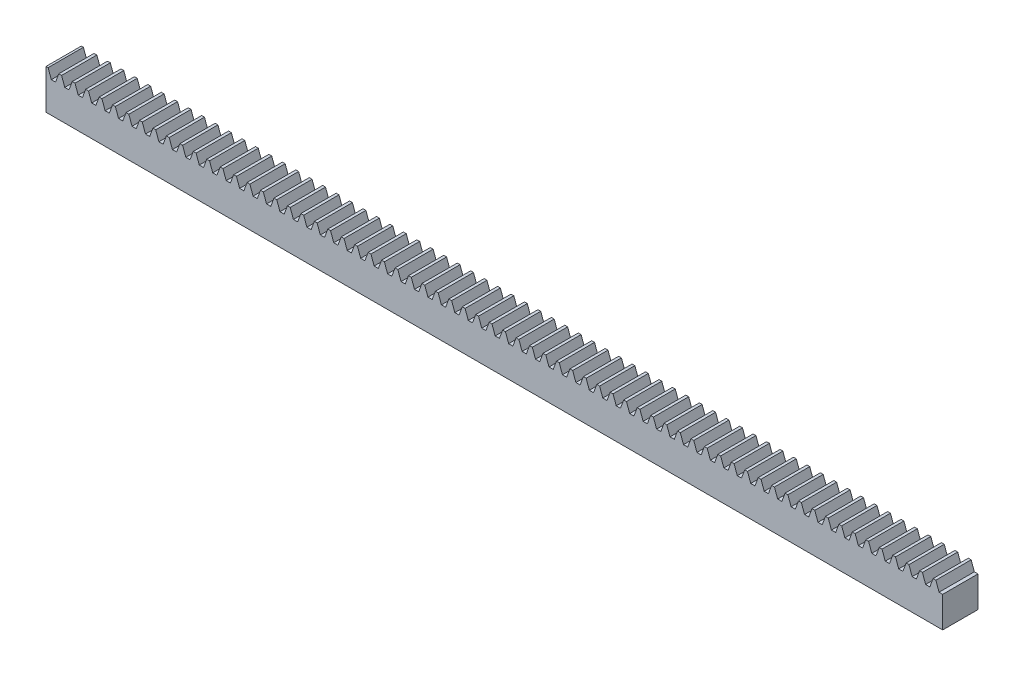
from build123d import *

# Parameters (mm, degrees)
SKETCH1_W           = 101.6
SKETCH1_H           = 4
BOSS_EXTRUDE1_DEPTH = 4.5
CUT_EXTRUDE1_DEPTH  = 5


with BuildPart() as part:
    # Sketch1 → Boss-Extrude1 (new body)
    with BuildSketch(Plane(origin=(0, 0, 0), x_dir=(1, 0, 0), z_dir=(0, 1, 0))):
        with Locations((50.8, 2)):
            Rectangle(SKETCH1_W, SKETCH1_H)
    extrude(amount=BOSS_EXTRUDE1_DEPTH)

    # Sketch2 → Cut-Extrude1 (cut, through all)
    with BuildSketch(Plane.XY):
        Polygon((0.239013956, 4.5), (0.60298419, 3.5), (0.841998146, 3.5), (1.081012101, 3.5), (1.444982335, 4.5), align=None)
        Polygon((1.763013956, 4.5), (2.12698419, 3.5), (2.365998146, 3.5), (2.605012101, 3.5), (2.968982335, 4.5), align=None)
        Polygon((3.287013956, 4.5), (3.65098419, 3.5), (3.889998146, 3.5), (4.129012101, 3.5), (4.492982335, 4.5), align=None)
        Polygon((4.811013956, 4.5), (5.17498419, 3.5), (5.413998146, 3.5), (5.653012101, 3.5), (6.016982335, 4.5), align=None)
        Polygon((6.335013956, 4.5), (6.69898419, 3.5), (6.937998146, 3.5), (7.177012101, 3.5), (7.540982335, 4.5), align=None)
        Polygon((7.859013956, 4.5), (8.22298419, 3.5), (8.461998146, 3.5), (8.701012101, 3.5), (9.064982335, 4.5), align=None)
        Polygon((9.383013956, 4.5), (9.74698419, 3.5), (9.985998146, 3.5), (10.225012101, 3.5), (10.588982335, 4.5), align=None)
        Polygon((10.907013956, 4.5), (11.27098419, 3.5), (11.509998146, 3.5), (11.749012101, 3.5), (12.112982335, 4.5), align=None)
        Polygon((12.431013956, 4.5), (12.79498419, 3.5), (13.033998146, 3.5), (13.273012101, 3.5), (13.636982335, 4.5), align=None)
        Polygon((13.955013956, 4.5), (14.31898419, 3.5), (14.557998146, 3.5), (14.797012101, 3.5), (15.160982335, 4.5), align=None)
        Polygon((15.479013956, 4.5), (15.84298419, 3.5), (16.081998146, 3.5), (16.321012101, 3.5), (16.684982335, 4.5), align=None)
        Polygon((17.003013956, 4.5), (17.36698419, 3.5), (17.605998146, 3.5), (17.845012101, 3.5), (18.208982335, 4.5), align=None)
        Polygon((18.527013956, 4.5), (18.89098419, 3.5), (19.129998146, 3.5), (19.369012101, 3.5), (19.732982335, 4.5), align=None)
        Polygon((20.051013956, 4.5), (20.41498419, 3.5), (20.653998146, 3.5), (20.893012101, 3.5), (21.256982335, 4.5), align=None)
        Polygon((21.575013956, 4.5), (21.93898419, 3.5), (22.177998146, 3.5), (22.417012101, 3.5), (22.780982335, 4.5), align=None)
        Polygon((23.099013956, 4.5), (23.46298419, 3.5), (23.701998146, 3.5), (23.941012101, 3.5), (24.304982335, 4.5), align=None)
        Polygon((24.623013956, 4.5), (24.98698419, 3.5), (25.225998146, 3.5), (25.465012101, 3.5), (25.828982335, 4.5), align=None)
        Polygon((26.147013956, 4.5), (26.51098419, 3.5), (26.749998146, 3.5), (26.989012101, 3.5), (27.352982335, 4.5), align=None)
        Polygon((27.671013956, 4.5), (28.03498419, 3.5), (28.273998146, 3.5), (28.513012101, 3.5), (28.876982335, 4.5), align=None)
        Polygon((29.195013956, 4.5), (29.55898419, 3.5), (29.797998146, 3.5), (30.037012101, 3.5), (30.400982335, 4.5), align=None)
        Polygon((30.719013956, 4.5), (31.08298419, 3.5), (31.321998146, 3.5), (31.561012101, 3.5), (31.924982335, 4.5), align=None)
        Polygon((32.243013956, 4.5), (32.60698419, 3.5), (32.845998146, 3.5), (33.085012101, 3.5), (33.448982335, 4.5), align=None)
        Polygon((33.767013956, 4.5), (34.13098419, 3.5), (34.369998146, 3.5), (34.609012101, 3.5), (34.972982335, 4.5), align=None)
        Polygon((35.291013956, 4.5), (35.65498419, 3.5), (35.893998146, 3.5), (36.133012101, 3.5), (36.496982335, 4.5), align=None)
        Polygon((36.815013956, 4.5), (37.17898419, 3.5), (37.417998146, 3.5), (37.657012101, 3.5), (38.020982335, 4.5), align=None)
        Polygon((38.339013956, 4.5), (38.70298419, 3.5), (38.941998146, 3.5), (39.181012101, 3.5), (39.544982335, 4.5), align=None)
        Polygon((39.863013956, 4.5), (40.22698419, 3.5), (40.465998146, 3.5), (40.705012101, 3.5), (41.068982335, 4.5), align=None)
        Polygon((41.387013956, 4.5), (41.75098419, 3.5), (41.989998146, 3.5), (42.229012101, 3.5), (42.592982335, 4.5), align=None)
        Polygon((42.911013956, 4.5), (43.27498419, 3.5), (43.513998146, 3.5), (43.753012101, 3.5), (44.116982335, 4.5), align=None)
        Polygon((44.435013956, 4.5), (44.79898419, 3.5), (45.037998146, 3.5), (45.277012101, 3.5), (45.640982335, 4.5), align=None)
        Polygon((45.959013956, 4.5), (46.32298419, 3.5), (46.561998146, 3.5), (46.801012101, 3.5), (47.164982335, 4.5), align=None)
        Polygon((47.483013956, 4.5), (47.84698419, 3.5), (48.085998146, 3.5), (48.325012101, 3.5), (48.688982335, 4.5), align=None)
        Polygon((49.007013956, 4.5), (49.37098419, 3.5), (49.609998146, 3.5), (49.849012101, 3.5), (50.212982335, 4.5), align=None)
        Polygon((50.531013956, 4.5), (50.89498419, 3.5), (51.133998146, 3.5), (51.373012101, 3.5), (51.736982335, 4.5), align=None)
        Polygon((52.055013956, 4.5), (52.41898419, 3.5), (52.657998146, 3.5), (52.897012101, 3.5), (53.260982335, 4.5), align=None)
        Polygon((53.579013956, 4.5), (53.94298419, 3.5), (54.181998146, 3.5), (54.421012101, 3.5), (54.784982335, 4.5), align=None)
        Polygon((55.103013956, 4.5), (55.46698419, 3.5), (55.705998146, 3.5), (55.945012101, 3.5), (56.308982335, 4.5), align=None)
        Polygon((56.627013956, 4.5), (56.99098419, 3.5), (57.229998146, 3.5), (57.469012101, 3.5), (57.832982335, 4.5), align=None)
        Polygon((58.151013956, 4.5), (58.51498419, 3.5), (58.753998146, 3.5), (58.993012101, 3.5), (59.356982335, 4.5), align=None)
        Polygon((59.675013956, 4.5), (60.03898419, 3.5), (60.277998146, 3.5), (60.517012101, 3.5), (60.880982335, 4.5), align=None)
        Polygon((61.199013956, 4.5), (61.56298419, 3.5), (61.801998146, 3.5), (62.041012101, 3.5), (62.404982335, 4.5), align=None)
        Polygon((62.723013956, 4.5), (63.08698419, 3.5), (63.325998146, 3.5), (63.565012101, 3.5), (63.928982335, 4.5), align=None)
        Polygon((64.247013956, 4.5), (64.61098419, 3.5), (64.849998146, 3.5), (65.089012101, 3.5), (65.452982335, 4.5), align=None)
        Polygon((65.771013956, 4.5), (66.13498419, 3.5), (66.373998146, 3.5), (66.613012101, 3.5), (66.976982335, 4.5), align=None)
        Polygon((67.295013956, 4.5), (67.65898419, 3.5), (67.897998146, 3.5), (68.137012101, 3.5), (68.500982335, 4.5), align=None)
        Polygon((68.819013956, 4.5), (69.18298419, 3.5), (69.421998146, 3.5), (69.661012101, 3.5), (70.024982335, 4.5), align=None)
        Polygon((70.343013956, 4.5), (70.70698419, 3.5), (70.945998146, 3.5), (71.185012101, 3.5), (71.548982335, 4.5), align=None)
        Polygon((71.867013956, 4.5), (72.23098419, 3.5), (72.469998146, 3.5), (72.709012101, 3.5), (73.072982335, 4.5), align=None)
        Polygon((73.391013956, 4.5), (73.75498419, 3.5), (73.993998146, 3.5), (74.233012101, 3.5), (74.596982335, 4.5), align=None)
        Polygon((74.915013956, 4.5), (75.27898419, 3.5), (75.517998146, 3.5), (75.757012101, 3.5), (76.120982335, 4.5), align=None)
        Polygon((76.439013956, 4.5), (76.80298419, 3.5), (77.041998146, 3.5), (77.281012101, 3.5), (77.644982335, 4.5), align=None)
        Polygon((77.963013956, 4.5), (78.32698419, 3.5), (78.565998146, 3.5), (78.805012101, 3.5), (79.168982335, 4.5), align=None)
        Polygon((79.487013956, 4.5), (79.85098419, 3.5), (80.089998146, 3.5), (80.329012101, 3.5), (80.692982335, 4.5), align=None)
        Polygon((81.011013956, 4.5), (81.37498419, 3.5), (81.613998146, 3.5), (81.853012101, 3.5), (82.216982335, 4.5), align=None)
        Polygon((82.535013956, 4.5), (82.89898419, 3.5), (83.137998146, 3.5), (83.377012101, 3.5), (83.740982335, 4.5), align=None)
        Polygon((84.059013956, 4.5), (84.42298419, 3.5), (84.661998146, 3.5), (84.901012101, 3.5), (85.264982335, 4.5), align=None)
        Polygon((85.583013956, 4.5), (85.94698419, 3.5), (86.185998146, 3.5), (86.425012101, 3.5), (86.788982335, 4.5), align=None)
        Polygon((87.107013956, 4.5), (87.47098419, 3.5), (87.709998146, 3.5), (87.949012101, 3.5), (88.312982335, 4.5), align=None)
        Polygon((88.631013956, 4.5), (88.99498419, 3.5), (89.233998146, 3.5), (89.473012101, 3.5), (89.836982335, 4.5), align=None)
        Polygon((90.155013956, 4.5), (90.51898419, 3.5), (90.757998146, 3.5), (90.997012101, 3.5), (91.360982335, 4.5), align=None)
        Polygon((91.679013956, 4.5), (92.04298419, 3.5), (92.281998146, 3.5), (92.521012101, 3.5), (92.884982335, 4.5), align=None)
        Polygon((93.203013956, 4.5), (93.56698419, 3.5), (93.805998146, 3.5), (94.045012101, 3.5), (94.408982335, 4.5), align=None)
        Polygon((94.727013956, 4.5), (95.09098419, 3.5), (95.329998146, 3.5), (95.569012101, 3.5), (95.932982335, 4.5), align=None)
        Polygon((96.251013956, 4.5), (96.61498419, 3.5), (96.853998146, 3.5), (97.093012101, 3.5), (97.456982335, 4.5), align=None)
        Polygon((97.775013956, 4.5), (98.13898419, 3.5), (98.377998146, 3.5), (98.617012101, 3.5), (98.980982335, 4.5), align=None)
        Polygon((99.299013956, 4.5), (99.66298419, 3.5), (99.901998146, 3.5), (100.141012101, 3.5), (100.504982335, 4.5), align=None)
        Polygon((100.823013956, 4.5), (101.18698419, 3.5), (101.425998146, 3.5), (101.665012101, 3.5), (102.028982335, 4.5), align=None)
        Polygon((102.347013956, 4.5), (102.71098419, 3.5), (102.949998146, 3.5), (103.189012101, 3.5), (103.552982335, 4.5), align=None)
        Polygon((103.871013956, 4.5), (104.23498419, 3.5), (104.473998146, 3.5), (104.713012101, 3.5), (105.076982335, 4.5), align=None)
        Polygon((105.395013956, 4.5), (105.75898419, 3.5), (105.997998146, 3.5), (106.237012101, 3.5), (106.600982335, 4.5), align=None)
        Polygon((106.919013956, 4.5), (107.28298419, 3.5), (107.521998146, 3.5), (107.761012101, 3.5), (108.124982335, 4.5), align=None)
        Polygon((108.443013956, 4.5), (108.80698419, 3.5), (109.045998146, 3.5), (109.285012101, 3.5), (109.648982335, 4.5), align=None)
        Polygon((109.967013956, 4.5), (110.33098419, 3.5), (110.569998146, 3.5), (110.809012101, 3.5), (111.172982335, 4.5), align=None)
        Polygon((111.491013956, 4.5), (111.85498419, 3.5), (112.093998146, 3.5), (112.333012101, 3.5), (112.696982335, 4.5), align=None)
        Polygon((113.015013956, 4.5), (113.37898419, 3.5), (113.617998146, 3.5), (113.857012101, 3.5), (114.220982335, 4.5), align=None)
        Polygon((114.539013956, 4.5), (114.90298419, 3.5), (115.141998146, 3.5), (115.381012101, 3.5), (115.744982335, 4.5), align=None)
        Polygon((116.063013956, 4.5), (116.42698419, 3.5), (116.665998146, 3.5), (116.905012101, 3.5), (117.268982335, 4.5), align=None)
        Polygon((117.587013956, 4.5), (117.95098419, 3.5), (118.189998146, 3.5), (118.429012101, 3.5), (118.792982335, 4.5), align=None)
        Polygon((119.111013956, 4.5), (119.47498419, 3.5), (119.713998146, 3.5), (119.953012101, 3.5), (120.316982335, 4.5), align=None)
        Polygon((120.635013956, 4.5), (120.99898419, 3.5), (121.237998146, 3.5), (121.477012101, 3.5), (121.840982335, 4.5), align=None)
        Polygon((122.159013956, 4.5), (122.52298419, 3.5), (122.761998146, 3.5), (123.001012101, 3.5), (123.364982335, 4.5), align=None)
        Polygon((123.683013956, 4.5), (124.04698419, 3.5), (124.285998146, 3.5), (124.525012101, 3.5), (124.888982335, 4.5), align=None)
        Polygon((125.207013956, 4.5), (125.57098419, 3.5), (125.809998146, 3.5), (126.049012101, 3.5), (126.412982335, 4.5), align=None)
        Polygon((126.731013956, 4.5), (127.09498419, 3.5), (127.333998146, 3.5), (127.573012101, 3.5), (127.936982335, 4.5), align=None)
        Polygon((128.255013956, 4.5), (128.61898419, 3.5), (128.857998146, 3.5), (129.097012101, 3.5), (129.460982335, 4.5), align=None)
        Polygon((129.779013956, 4.5), (130.14298419, 3.5), (130.381998146, 3.5), (130.621012101, 3.5), (130.984982335, 4.5), align=None)
        Polygon((131.303013956, 4.5), (131.66698419, 3.5), (131.905998146, 3.5), (132.145012101, 3.5), (132.508982335, 4.5), align=None)
        Polygon((132.827013956, 4.5), (133.19098419, 3.5), (133.429998146, 3.5), (133.669012101, 3.5), (134.032982335, 4.5), align=None)
        Polygon((134.351013956, 4.5), (134.71498419, 3.5), (134.953998146, 3.5), (135.193012101, 3.5), (135.556982335, 4.5), align=None)
        Polygon((135.875013956, 4.5), (136.23898419, 3.5), (136.477998146, 3.5), (136.717012101, 3.5), (137.080982335, 4.5), align=None)
        Polygon((137.399013956, 4.5), (137.76298419, 3.5), (138.001998146, 3.5), (138.241012101, 3.5), (138.604982335, 4.5), align=None)
        Polygon((138.923013956, 4.5), (139.28698419, 3.5), (139.525998146, 3.5), (139.765012101, 3.5), (140.128982335, 4.5), align=None)
        Polygon((140.447013956, 4.5), (140.81098419, 3.5), (141.049998146, 3.5), (141.289012101, 3.5), (141.652982335, 4.5), align=None)
        Polygon((141.971013956, 4.5), (142.33498419, 3.5), (142.573998146, 3.5), (142.813012101, 3.5), (143.176982335, 4.5), align=None)
        Polygon((143.495013956, 4.5), (143.85898419, 3.5), (144.097998146, 3.5), (144.337012101, 3.5), (144.700982335, 4.5), align=None)
        Polygon((145.019013956, 4.5), (145.38298419, 3.5), (145.621998146, 3.5), (145.861012101, 3.5), (146.224982335, 4.5), align=None)
        Polygon((146.543013956, 4.5), (146.90698419, 3.5), (147.145998146, 3.5), (147.385012101, 3.5), (147.748982335, 4.5), align=None)
        Polygon((148.067013956, 4.5), (148.43098419, 3.5), (148.669998146, 3.5), (148.909012101, 3.5), (149.272982335, 4.5), align=None)
        Polygon((149.591013956, 4.5), (149.95498419, 3.5), (150.193998146, 3.5), (150.433012101, 3.5), (150.796982335, 4.5), align=None)
        Polygon((151.115013956, 4.5), (151.47898419, 3.5), (151.717998146, 3.5), (151.957012101, 3.5), (152.320982335, 4.5), align=None)
        Polygon((152.639013956, 4.5), (153.00298419, 3.5), (153.241998146, 3.5), (153.481012101, 3.5), (153.844982335, 4.5), align=None)
        Polygon((154.163013956, 4.5), (154.52698419, 3.5), (154.765998146, 3.5), (155.005012101, 3.5), (155.368982335, 4.5), align=None)
        Polygon((155.687013956, 4.5), (156.05098419, 3.5), (156.289998146, 3.5), (156.529012101, 3.5), (156.892982335, 4.5), align=None)
        Polygon((157.211013956, 4.5), (157.57498419, 3.5), (157.813998146, 3.5), (158.053012101, 3.5), (158.416982335, 4.5), align=None)
        Polygon((158.735013956, 4.5), (159.09898419, 3.5), (159.337998146, 3.5), (159.577012101, 3.5), (159.940982335, 4.5), align=None)
        Polygon((160.259013956, 4.5), (160.62298419, 3.5), (160.861998146, 3.5), (161.101012101, 3.5), (161.464982335, 4.5), align=None)
        Polygon((161.783013956, 4.5), (162.14698419, 3.5), (162.385998146, 3.5), (162.625012101, 3.5), (162.988982335, 4.5), align=None)
        Polygon((163.307013956, 4.5), (163.67098419, 3.5), (163.909998146, 3.5), (164.149012101, 3.5), (164.512982335, 4.5), align=None)
        Polygon((164.831013956, 4.5), (165.19498419, 3.5), (165.433998146, 3.5), (165.673012101, 3.5), (166.036982335, 4.5), align=None)
        Polygon((166.355013956, 4.5), (166.71898419, 3.5), (166.957998146, 3.5), (167.197012101, 3.5), (167.560982335, 4.5), align=None)
        Polygon((167.879013956, 4.5), (168.24298419, 3.5), (168.481998146, 3.5), (168.721012101, 3.5), (169.084982335, 4.5), align=None)
        Polygon((169.403013956, 4.5), (169.76698419, 3.5), (170.005998146, 3.5), (170.245012101, 3.5), (170.608982335, 4.5), align=None)
        Polygon((170.927013956, 4.5), (171.29098419, 3.5), (171.529998146, 3.5), (171.769012101, 3.5), (172.132982335, 4.5), align=None)
        Polygon((172.451013956, 4.5), (172.81498419, 3.5), (173.053998146, 3.5), (173.293012101, 3.5), (173.656982335, 4.5), align=None)
        Polygon((173.975013956, 4.5), (174.33898419, 3.5), (174.577998146, 3.5), (174.817012101, 3.5), (175.180982335, 4.5), align=None)
        Polygon((175.499013956, 4.5), (175.86298419, 3.5), (176.101998146, 3.5), (176.341012101, 3.5), (176.704982335, 4.5), align=None)
        Polygon((177.023013956, 4.5), (177.38698419, 3.5), (177.625998146, 3.5), (177.865012101, 3.5), (178.228982335, 4.5), align=None)
        Polygon((178.547013956, 4.5), (178.91098419, 3.5), (179.149998146, 3.5), (179.389012101, 3.5), (179.752982335, 4.5), align=None)
        Polygon((180.071013956, 4.5), (180.43498419, 3.5), (180.673998146, 3.5), (180.913012101, 3.5), (181.276982335, 4.5), align=None)
        Polygon((181.595013956, 4.5), (181.95898419, 3.5), (182.197998146, 3.5), (182.437012101, 3.5), (182.800982335, 4.5), align=None)
        Polygon((183.119013956, 4.5), (183.48298419, 3.5), (183.721998146, 3.5), (183.961012101, 3.5), (184.324982335, 4.5), align=None)
        Polygon((184.643013956, 4.5), (185.00698419, 3.5), (185.245998146, 3.5), (185.485012101, 3.5), (185.848982335, 4.5), align=None)
        Polygon((186.167013956, 4.5), (186.53098419, 3.5), (186.769998146, 3.5), (187.009012101, 3.5), (187.372982335, 4.5), align=None)
        Polygon((187.691013956, 4.5), (188.05498419, 3.5), (188.293998146, 3.5), (188.533012101, 3.5), (188.896982335, 4.5), align=None)
        Polygon((189.215013956, 4.5), (189.57898419, 3.5), (189.817998146, 3.5), (190.057012101, 3.5), (190.420982335, 4.5), align=None)
    extrude(amount=-CUT_EXTRUDE1_DEPTH, mode=Mode.SUBTRACT)


solid = part.part
